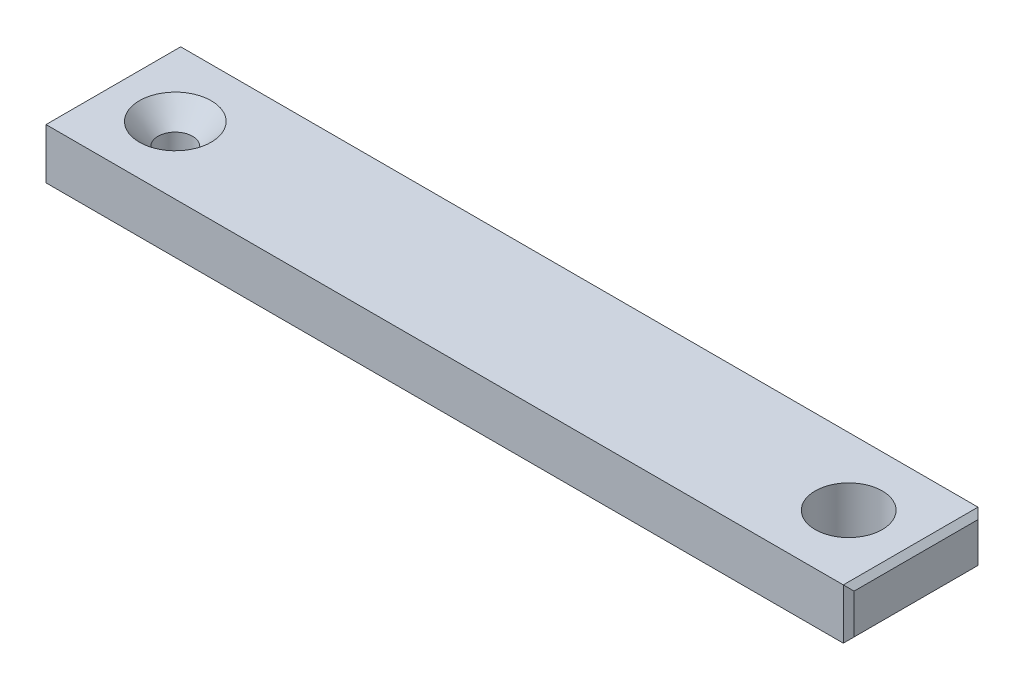
from build123d import *

# Parameters (mm, degrees)
SKETCH1_W                                         = 76.2
SKETCH1_H                                         = 12.7
BOSS_EXTRUDE2_DEPTH                               = 4.7625
CSK_FOR_4_FLAT_HEAD_SOCKET_CAP_SCREW1_D           = 3.2639
CSK_FOR_4_FLAT_HEAD_SOCKET_CAP_SCREW1_CSINK_D     = 6.7818
CSK_FOR_4_FLAT_HEAD_SOCKET_CAP_SCREW1_CSINK_ANGLE = 82
CUT_EXTRUDE1_DEPTH                                = 5.7625
CHAMFER1_SIZE                                     = 0.508


with BuildPart() as part:
    # Sketch1 → Boss-Extrude2 (new body)
    with BuildSketch(Plane(origin=(0, 0, 0), x_dir=(1, 0, 0), z_dir=(0, 1, 0))):
        with Locations((-31.75, 0)):
            Rectangle(SKETCH1_W, SKETCH1_H)
    extrude(amount=BOSS_EXTRUDE2_DEPTH)

    # CSK for #4 Flat Head Socket Cap Screw1 (through all)
    with Locations(Plane(origin=(0, 4.7625, 0), x_dir=(1, 0, 0), z_dir=(0, 1, 0))):
        with Locations((-63.5, 0)):
            CounterSinkHole(CSK_FOR_4_FLAT_HEAD_SOCKET_CAP_SCREW1_D / 2, CSK_FOR_4_FLAT_HEAD_SOCKET_CAP_SCREW1_CSINK_D / 2, counter_sink_angle=CSK_FOR_4_FLAT_HEAD_SOCKET_CAP_SCREW1_CSINK_ANGLE)

    # Sketch2 → Cut-Extrude1 (cut, through all)
    with BuildSketch(Plane(origin=(0, 4.7625, 0), x_dir=(1, 0, 0), z_dir=(0, 1, 0))):
        with BuildLine():
            ThreePointArc((3.1623, 0), (2.236083774, 2.236083774), (0, 3.1623))
            Line((0, 3.1623), (0, -3.1623))
            ThreePointArc((0, -3.1623), (2.236083774, -2.236083774), (3.1623, 0))
        make_face()
        with BuildLine():
            Line((0, -3.1623), (0, 3.1623))
            ThreePointArc((0, 3.1623), (-3.1623, 0), (0, -3.1623))
        make_face()
    extrude(amount=-CUT_EXTRUDE1_DEPTH, mode=Mode.SUBTRACT)

    # Chamfer1
    chamfer1_edges = [part.edges().sort_by_distance(p)[0] for p in [
        (-69.85, 2.38125, 6.35),
        (-69.85, 2.38125, -6.35),
        (6.35, 2.38125, -6.35),
        (6.35, 2.38125, 6.35),
        (6.35, 4.7625, 0),
        (-69.85, 4.7625, 0),
        (-69.85, 0, 0),
        (6.35, 0, 0),
    ]]
    chamfer(chamfer1_edges, length=CHAMFER1_SIZE)


solid = part.part
